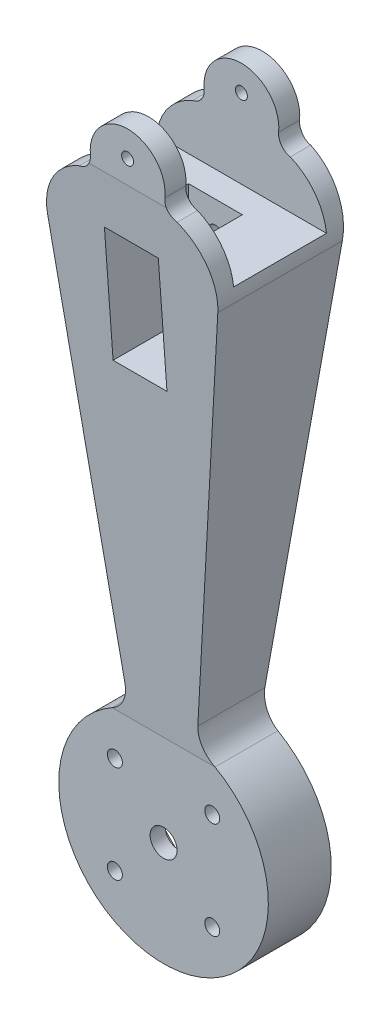
from build123d import *

# Parameters (mm, degrees)
BOSS_EXTRUDE1_DEPTH      = 45
CUT_EXTRUDE2_DEPTH       = 36
CUT_EXTRUDE2_DEPTH_BACK  = 36
CUT_EXTRUDE3_DEPTH       = 28
SKETCH6_R                = 4.5
SKETCH6_R_2              = 2.5
CUT_EXTRUDE4_DEPTH       = 29
CUT_EXTRUDE4_DEPTH_BACK  = 18
CUT_EXTRUDE6_DEPTH       = 10
SKETCH12_W               = 33
SKETCH12_H               = 40
CUT_EXTRUDE9_DEPTH       = 9
CUT_EXTRUDE9_DEPTH_BACK  = 9
SKETCH13_W               = 31
SKETCH13_H               = 35
CUT_EXTRUDE10_DEPTH      = 36
CUT_EXTRUDE10_DEPTH_BACK = 36
SKETCH14_R               = 2
CUT_EXTRUDE13_DEPTH      = 46
CUT_EXTRUDE13_DEPTH_BACK = 9
SKETCH15_R               = 2.5
CUT_EXTRUDE14_DEPTH      = 16.676509358


with BuildPart() as part:
    # Sketch1 → Boss-Extrude1 (new body)
    with BuildSketch(Plane.XY):
        with BuildLine():
            Line((-12.137605226, 40.130176139), (-28.41462727, 172.695882476))
            ThreePointArc((-28.41462727, 172.695882476), (-25.871526221, 185.155210183), (-16.331642516, 193.563112938))
            ThreePointArc((-16.331642516, 193.563112938), (-13.372104724, 195.395277041), (-12.437153877, 198.748120036))
            ThreePointArc((-12.437153877, 198.748120036), (0, 212.5), (12.437153877, 198.748120036))
            ThreePointArc((12.437153877, 198.748120036), (13.372104724, 195.395277041), (16.331642516, 193.563112938))
            ThreePointArc((16.331642516, 193.563112938), (25.871526221, 185.155210183), (28.41462727, 172.695882476))
            Line((28.41462727, 172.695882476), (12.137605226, 40.130176139))
            ThreePointArc((12.137605226, 40.130176139), (13.235334505, 34.563989878), (17.184596043, 30.490812695))
            ThreePointArc((17.184596043, 30.490812695), (0, -35), (-17.184596043, 30.490812695))
            ThreePointArc((-17.184596043, 30.490812695), (-13.235334505, 34.563989878), (-12.137605226, 40.130176139))
        make_face()
    extrude(amount=BOSS_EXTRUDE1_DEPTH)

    # Sketch4 → Cut-Extrude2 (cut, two sides)
    with BuildSketch(Plane(origin=(0, 0, 0), x_dir=(0, 0, -1), z_dir=(1, 0, 0))) as cut_extrude2_sk:
        Polygon((-45, 196.155616487), (-33, 30.490812695), (-33, -35), (-45, -35), align=None)
        Polygon((-12, -35), (0, -35), (0, 196.155616487), (-12, 30.490812695), align=None)
    extrude(amount=CUT_EXTRUDE2_DEPTH, mode=Mode.SUBTRACT)
    extrude(cut_extrude2_sk.sketch, amount=-CUT_EXTRUDE2_DEPTH_BACK, mode=Mode.SUBTRACT)

    # Sketch5 → Cut-Extrude3 (cut)
    with BuildSketch(Plane.XY):
        Polygon((16.97, -20.5), (-16.97, -20.5), (-20.5, -16.97), (-20.5, 16.97), (-16.97, 20.5), (16.97, 20.5), (20.5, 16.97), (20.5, -16.97), align=None)
    extrude(amount=CUT_EXTRUDE3_DEPTH, mode=Mode.SUBTRACT)

    # Sketch6 → Cut-Extrude4 (cut, two sides)
    with BuildSketch(Plane(origin=(0, 0, 28), x_dir=(-1, 0, 0), z_dir=(0, 0, -1))) as cut_extrude4_sk:
        Circle(SKETCH6_R)
        with Locations((-16.257359313, 16.257359313)):
            Circle(SKETCH6_R_2)
        with Locations((16.260126266, 16.260126266)):
            Circle(SKETCH6_R_2)
        with Locations((-16.260126266, -16.260126266)):
            Circle(SKETCH6_R_2)
        with Locations((16.260126266, -16.260126266)):
            Circle(SKETCH6_R_2)
    extrude(amount=CUT_EXTRUDE4_DEPTH, mode=Mode.SUBTRACT)
    extrude(cut_extrude4_sk.sketch, amount=-CUT_EXTRUDE4_DEPTH_BACK, mode=Mode.SUBTRACT)

    # Sketch8 → Cut-Extrude6 (cut, along a direction that is not the sketch's normal)
    with BuildSketch(Plane(origin=(0, 1.023835067, 14.134452964), x_dir=(-1, 0, 0), z_dir=(0, -0.072246136, -0.997386834))):
        with BuildLine():
            Line((-2.88453501, 56.792957469), (-14.82487519, 154.294010847))
            ThreePointArc((-14.82487519, 154.294010847), (0.17238227, 165.145626965), (15.16963973, 154.294010847))
            Line((15.16963973, 154.294010847), (3.214085595, 56.668725114))
            ThreePointArc((3.214085595, 56.668725114), (0.089957546, 53.058005434), (-2.88453501, 56.792957469))
        make_face()
    extrude(amount=-CUT_EXTRUDE6_DEPTH, dir=(0, 0.072246136, -0.997386834), mode=Mode.SUBTRACT)

    # Sketch12 → Cut-Extrude9 (cut, two sides)
    with BuildSketch(Plane(origin=(0, 0, 0), x_dir=(0, 0, -1), z_dir=(1, 0, 0))) as cut_extrude9_sk:
        with Locations((-32.176509358, 158.99066374)):
            Rectangle(SKETCH12_W, SKETCH12_H)
    extrude(amount=CUT_EXTRUDE9_DEPTH, mode=Mode.SUBTRACT)
    extrude(cut_extrude9_sk.sketch, amount=-CUT_EXTRUDE9_DEPTH_BACK, mode=Mode.SUBTRACT)

    # Sketch13 → Cut-Extrude10 (cut, two sides)
    with BuildSketch(Plane(origin=(0, 0, 0), x_dir=(0, 0, -1), z_dir=(1, 0, 0))) as cut_extrude10_sk:
        with Locations((-22.5, 195)):
            Rectangle(SKETCH13_W, SKETCH13_H)
    extrude(amount=CUT_EXTRUDE10_DEPTH, mode=Mode.SUBTRACT)
    extrude(cut_extrude10_sk.sketch, amount=-CUT_EXTRUDE10_DEPTH_BACK, mode=Mode.SUBTRACT)

    # Sketch14 → Cut-Extrude13 (cut, two sides)
    with BuildSketch(Plane.XY) as cut_extrude13_sk:
        with Locations((0, 203.896404583)):
            Circle(SKETCH14_R)
    extrude(amount=CUT_EXTRUDE13_DEPTH, mode=Mode.SUBTRACT)
    extrude(cut_extrude13_sk.sketch, amount=-CUT_EXTRUDE13_DEPTH_BACK, mode=Mode.SUBTRACT)

    # Sketch15 → Cut-Extrude14 (cut, through all)
    with BuildSketch(Plane.XY.offset(15.676509358)):
        with Locations((0, 167.5)):
            Circle(SKETCH15_R)
    extrude(amount=-CUT_EXTRUDE14_DEPTH, mode=Mode.SUBTRACT)


solid = part.part
